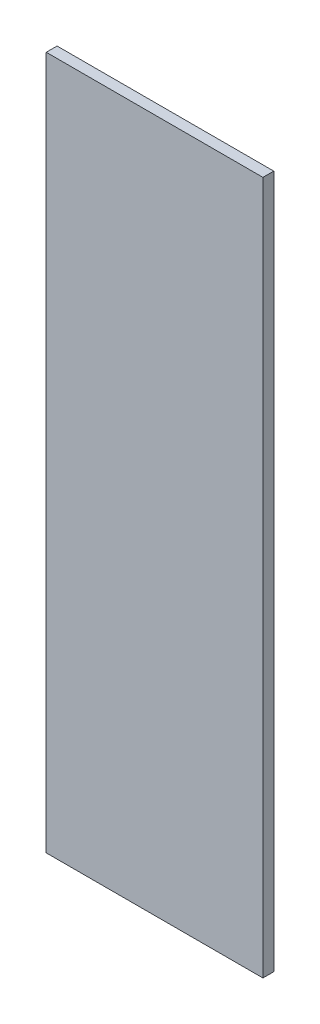
from build123d import *

# Parameters (mm, degrees)
SKETCH1_W           = 100
SKETCH1_H           = 320
BOSS_EXTRUDE1_DEPTH = 5


with BuildPart() as part:
    # Sketch1 → Boss-Extrude1 (new body)
    with BuildSketch(Plane.XY):
        Rectangle(SKETCH1_W, SKETCH1_H)
    extrude(amount=BOSS_EXTRUDE1_DEPTH)


solid = part.part
